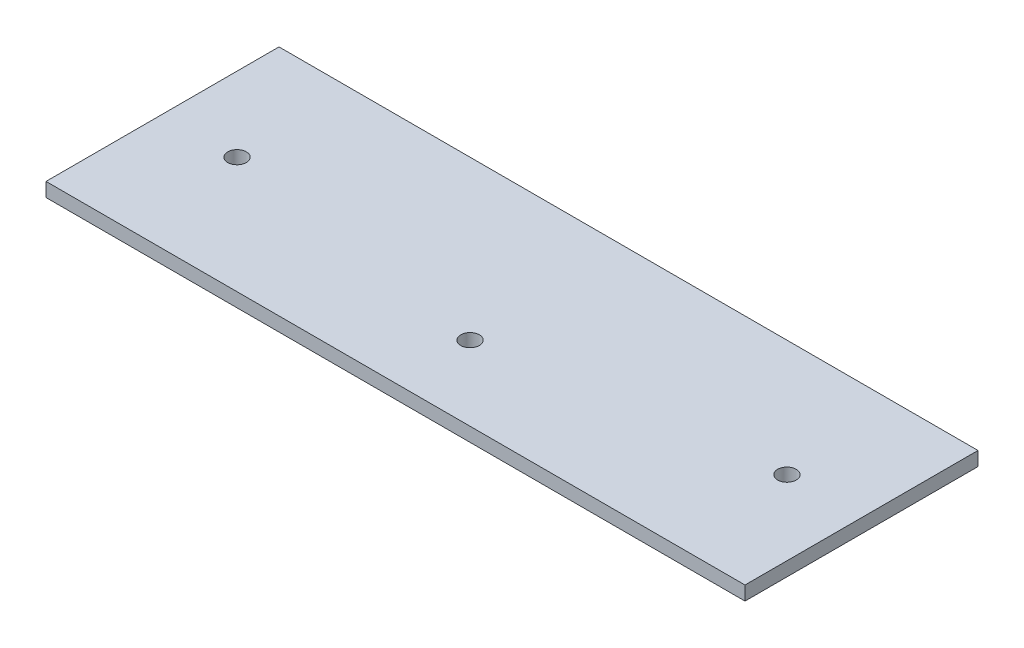
from build123d import *

# Parameters (mm, degrees)
SKETCH1_W           = 150
SKETCH1_H           = 50
BOSS_EXTRUDE1_DEPTH = 3
SKETCH2_R           = 2
CUT_EXTRUDE1_DEPTH  = 3
CUT_EXTRUDE2_REACH  = 5
SKETCH3_R           = 2


with BuildPart() as part:
    # Sketch1 → Boss-Extrude1 (new body)
    with BuildSketch(Plane(origin=(0, 0, 0), x_dir=(1, 0, 0), z_dir=(0, 1, 0))):
        Rectangle(SKETCH1_W, SKETCH1_H)
    extrude(amount=BOSS_EXTRUDE1_DEPTH)

    # Sketch2 → Cut-Extrude1 (cut)
    with BuildSketch(Plane(origin=(0, 3, 0), x_dir=(1, 0, 0), z_dir=(0, 1, 0))):
        with Locations(Location((59, 0, 0), (0, 0, 270))):  # turned: the seam where the file's is
            Circle(SKETCH2_R)
    cut_extrude1 = extrude(amount=-CUT_EXTRUDE1_DEPTH, mode=Mode.SUBTRACT)

    # Mirror1: Cut-Extrude1 across plane
    add(cut_extrude1.mirror(Plane(origin=(0, 0, 0), x_dir=(0, 0, 1), z_dir=(1, 0, 0))), mode=Mode.SUBTRACT)

    # Sketch3 → Cut-Extrude2 (cut, up to next)
    with BuildSketch(Plane(origin=(0, 3, 0), x_dir=(1, 0, 0), z_dir=(0, 1, 0)), mode=Mode.PRIVATE) as cut_extrude2_sk1:
        with Locations(Location((0, -9, 0), (0, 0, 270))):  # turned: the seam where the file's is
            Circle(SKETCH3_R)
    cut_extrude2_tool1 = extrude(cut_extrude2_sk1.sketch, amount=-CUT_EXTRUDE2_REACH, mode=Mode.PRIVATE) & part.part
    add(cut_extrude2_tool1.solids().sort_by_distance((0, 3, 9))[0], mode=Mode.SUBTRACT)


solid = part.part
